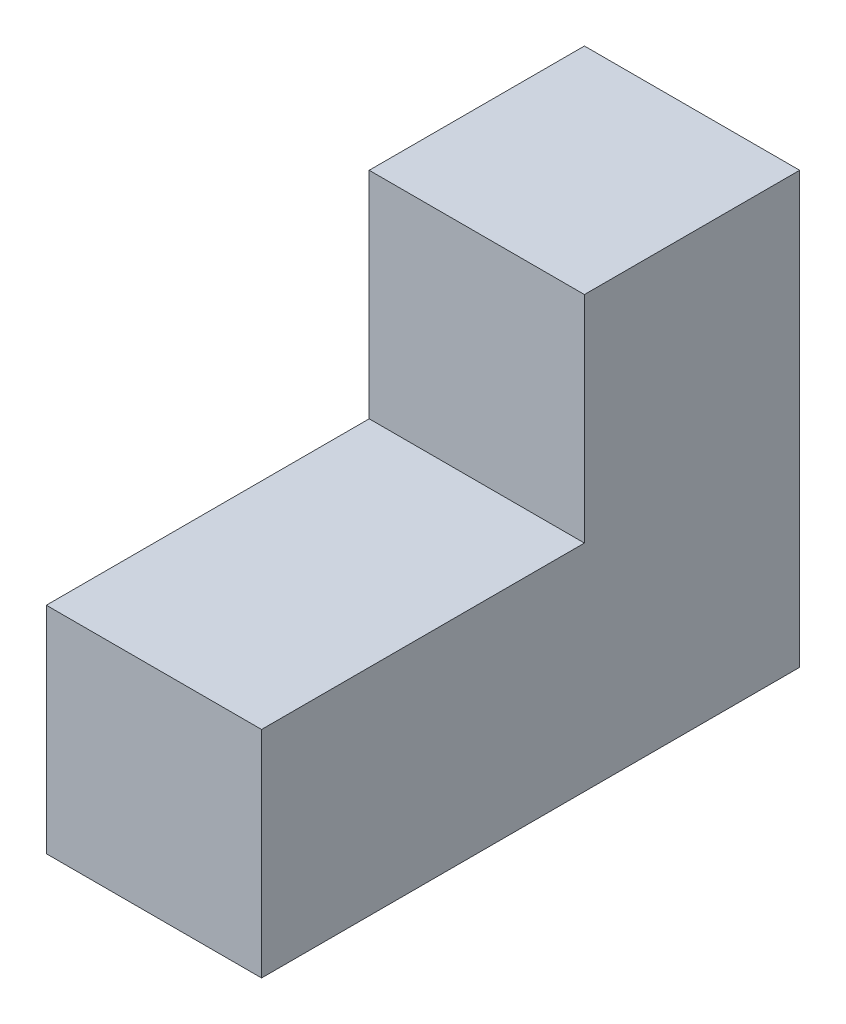
from build123d import *

# Parameters (mm, degrees)
BOSS_EXTRUDE1_DEPTH = 20


with BuildPart() as part:
    # Sketch1 → Boss-Extrude1 (new body)
    with BuildSketch(Plane(origin=(0, 0, 0), x_dir=(0, 0, -1), z_dir=(1, 0, 0))):
        Polygon((0, 0), (50, 0), (50, 40), (30, 40), (30, 20), (0, 20), align=None)
    extrude(amount=BOSS_EXTRUDE1_DEPTH)


solid = part.part
